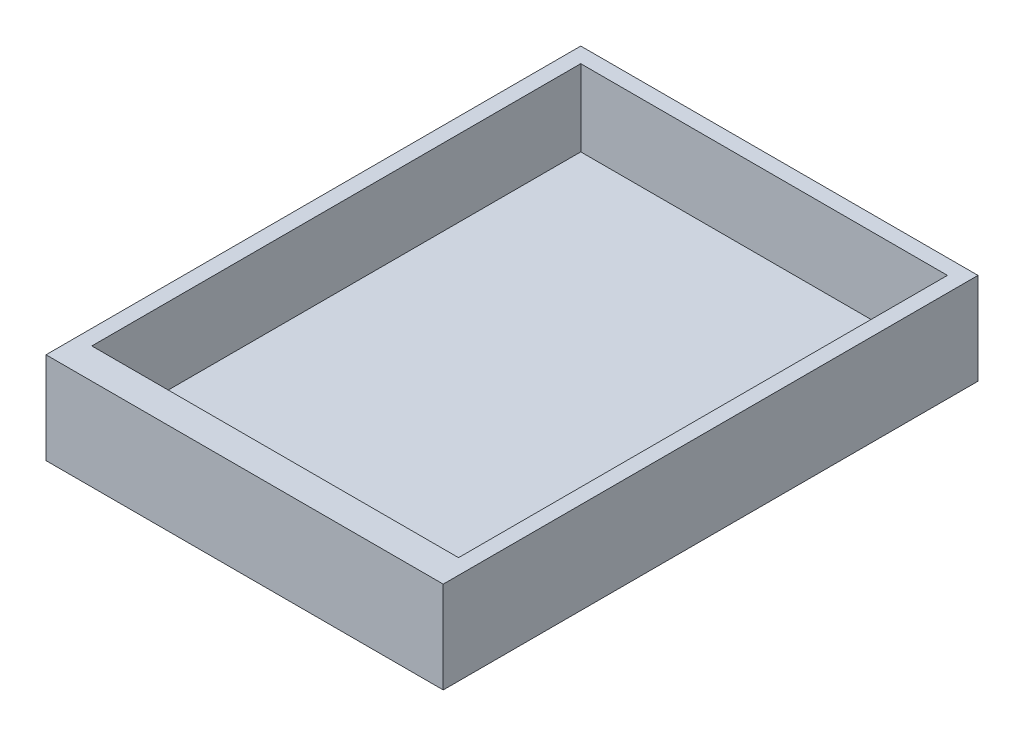
from build123d import *

# Parameters (mm, degrees)
SKETCH1_W           = 82.55
SKETCH1_H           = 111.125
BOSS_EXTRUDE1_DEPTH = 19.05
SKETCH14_W          = 76.2
SKETCH14_H          = 101.6
CUT_EXTRUDE3_DEPTH  = 15.875


with BuildPart() as part:
    # Sketch1 → Boss-Extrude1 (new body)
    with BuildSketch(Plane(origin=(0, 0, 0), x_dir=(1, 0, 0), z_dir=(0, 1, 0))):
        Rectangle(SKETCH1_W, SKETCH1_H)
    extrude(amount=BOSS_EXTRUDE1_DEPTH)

    # Sketch14 → Cut-Extrude3 (cut)
    with BuildSketch(Plane(origin=(0, 19.05, 0), x_dir=(-1, 0, 0), z_dir=(0, 1, 0))):
        with Locations((0, -1.5875)):
            Rectangle(SKETCH14_W, SKETCH14_H)
    extrude(amount=-CUT_EXTRUDE3_DEPTH, mode=Mode.SUBTRACT)


solid = part.part
